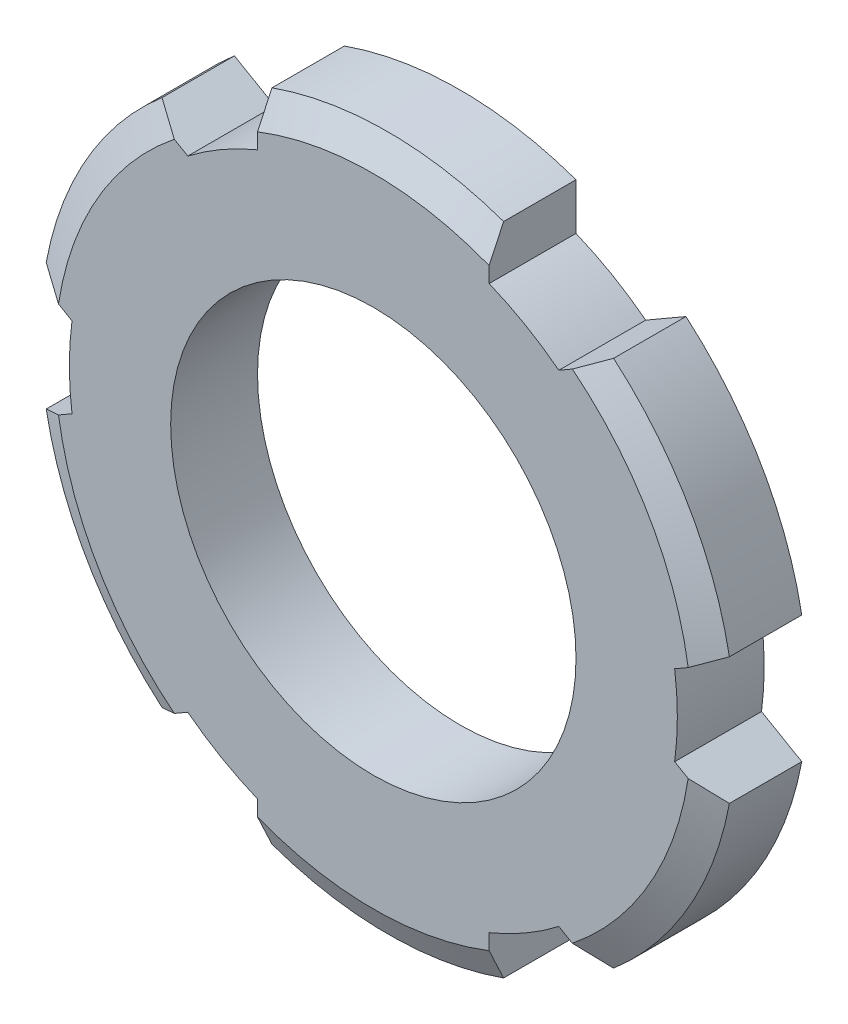
from build123d import *

# Parameters (mm, degrees)
EXTRUSION1_DEPTH        = 3
TROU_TARAUD_M161_D      = 14
CHANFREIN2_SIZE         = 0.5
CHANFREIN2_SIZE2        = 1
CHANFREIN2_PART_2_SIZE  = 0.5
CHANFREIN2_PART_2_SIZE2 = 1
CHANFREIN2_PART_3_SIZE  = 0.5
CHANFREIN2_PART_3_SIZE2 = 1
CHANFREIN2_PART_4_SIZE  = 0.5
CHANFREIN2_PART_4_SIZE2 = 1
CHANFREIN2_PART_5_SIZE  = 0.5
CHANFREIN2_PART_5_SIZE2 = 1
CHANFREIN2_PART_6_SIZE  = 0.5
CHANFREIN2_PART_6_SIZE2 = 1


with BuildPart() as part:
    # Esquisse1 → Extrusion1 (new body)
    with BuildSketch(Plane.XY):
        with BuildLine():
            Line((7.797958971, 9.120955865), (6.40758586, 8.318223575))
            ThreePointArc((6.40758586, 8.318223575), (5.25, 9.09326674), (4, 9.708243919))
            Line((4, 9.708243919), (4, 11.313708499))
            ThreePointArc((4, 11.313708499), (0, 12), (-4, 11.313708499))
            Line((-4, 11.313708499), (-4, 9.708243919))
            ThreePointArc((-4, 9.708243919), (-5.25, 9.09326674), (-6.40758586, 8.318223575))
            Line((-6.40758586, 8.318223575), (-7.797958971, 9.120955865))
            ThreePointArc((-7.797958971, 9.120955865), (-10.392304845, 6), (-11.797958971, 2.192752634))
            Line((-11.797958971, 2.192752634), (-10.40758586, 1.390020345))
            ThreePointArc((-10.40758586, 1.390020345), (-10.5, 0), (-10.40758586, -1.390020345))
            Line((-10.40758586, -1.390020345), (-11.797958971, -2.192752634))
            ThreePointArc((-11.797958971, -2.192752634), (-10.392304845, -6), (-7.797958971, -9.120955865))
            Line((-7.797958971, -9.120955865), (-6.40758586, -8.318223575))
            ThreePointArc((-6.40758586, -8.318223575), (-5.25, -9.09326674), (-4, -9.708243919))
            Line((-4, -9.708243919), (-4, -11.313708499))
            ThreePointArc((-4, -11.313708499), (0, -12), (4, -11.313708499))
            Line((4, -11.313708499), (4, -9.708243919))
            ThreePointArc((4, -9.708243919), (5.25, -9.09326674), (6.40758586, -8.318223575))
            Line((6.40758586, -8.318223575), (7.797958971, -9.120955865))
            ThreePointArc((7.797958971, -9.120955865), (10.392304845, -6), (11.797958971, -2.192752634))
            Line((11.797958971, -2.192752634), (10.40758586, -1.390020345))
            ThreePointArc((10.40758586, -1.390020345), (10.5, 0), (10.40758586, 1.390020345))
            Line((10.40758586, 1.390020345), (11.797958971, 2.192752634))
            ThreePointArc((11.797958971, 2.192752634), (10.392304845, 6), (7.797958971, 9.120955865))
        make_face()
    extrude(amount=EXTRUSION1_DEPTH)

    # Trou taraudé M161 (through all)
    with Locations(Plane.XY.offset(3)):
        with Locations((0, 0)):
            Hole(TROU_TARAUD_M161_D / 2)

    # Chanfrein2
    chanfrein2_edges = [part.edges().sort_by_distance(p)[0] for p in [
        (-10.392304845, 6, 3),
    ]]
    chanfrein2_side = [part.faces().sort_by_distance(p)[0] for p in [
        (-10.392304845, 6, 1.5),
    ]]
    chamfer(chanfrein2_edges, length=CHANFREIN2_SIZE, length2=CHANFREIN2_SIZE2, reference=chanfrein2_side[0])

    # Chanfrein2 part 2
    chanfrein2_part_2_edges = [part.edges().sort_by_distance(p)[0] for p in [
        (-10.392304845, -6, 3),
    ]]
    chanfrein2_part_2_side = [part.faces().sort_by_distance(p)[0] for p in [
        (-10.392304845, -6, 1.5),
    ]]
    chamfer(chanfrein2_part_2_edges, length=CHANFREIN2_PART_2_SIZE, length2=CHANFREIN2_PART_2_SIZE2, reference=chanfrein2_part_2_side[0])

    # Chanfrein2 part 3
    chanfrein2_part_3_edges = [part.edges().sort_by_distance(p)[0] for p in [
        (0, 12, 3),
    ]]
    chanfrein2_part_3_side = [part.faces().sort_by_distance(p)[0] for p in [
        (0, 12, 1.5),
    ]]
    chamfer(chanfrein2_part_3_edges, length=CHANFREIN2_PART_3_SIZE, length2=CHANFREIN2_PART_3_SIZE2, reference=chanfrein2_part_3_side[0])

    # Chanfrein2 part 4
    chanfrein2_part_4_edges = [part.edges().sort_by_distance(p)[0] for p in [
        (0, -12, 3),
    ]]
    chanfrein2_part_4_side = [part.faces().sort_by_distance(p)[0] for p in [
        (0, -12, 1.5),
    ]]
    chamfer(chanfrein2_part_4_edges, length=CHANFREIN2_PART_4_SIZE, length2=CHANFREIN2_PART_4_SIZE2, reference=chanfrein2_part_4_side[0])

    # Chanfrein2 part 5
    chanfrein2_part_5_edges = [part.edges().sort_by_distance(p)[0] for p in [
        (10.392304845, -6, 3),
    ]]
    chanfrein2_part_5_side = [part.faces().sort_by_distance(p)[0] for p in [
        (10.392304845, -6, 1.5),
    ]]
    chamfer(chanfrein2_part_5_edges, length=CHANFREIN2_PART_5_SIZE, length2=CHANFREIN2_PART_5_SIZE2, reference=chanfrein2_part_5_side[0])

    # Chanfrein2 part 6
    chanfrein2_part_6_edges = [part.edges().sort_by_distance(p)[0] for p in [
        (10.392304845, 6, 3),
    ]]
    chanfrein2_part_6_side = [part.faces().sort_by_distance(p)[0] for p in [
        (10.392304845, 6, 1.5),
    ]]
    chamfer(chanfrein2_part_6_edges, length=CHANFREIN2_PART_6_SIZE, length2=CHANFREIN2_PART_6_SIZE2, reference=chanfrein2_part_6_side[0])


solid = part.part
